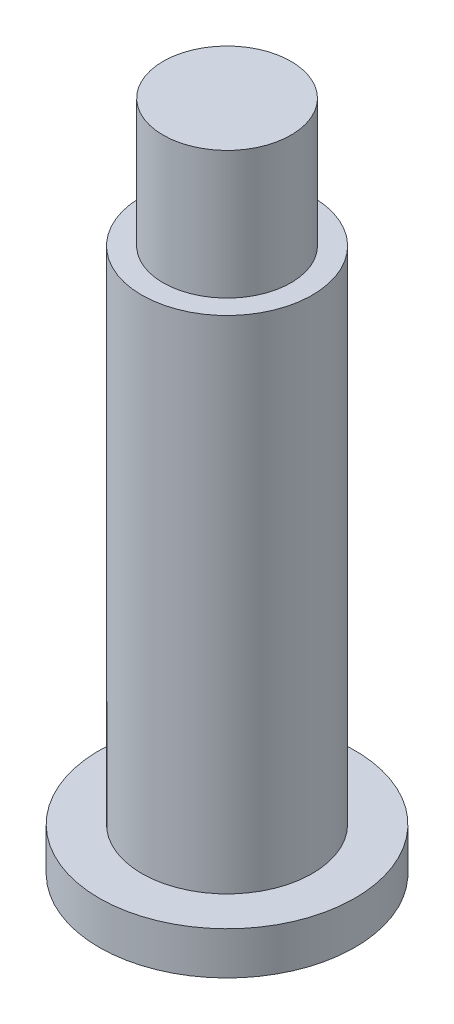
from build123d import *

# Parameters (mm, degrees)
SKETCH_1_R      = 6
EXTRUDE_1_DEPTH = 2
SKETCH_2_R      = 4
EXTRUDE_2_DEPTH = 23.5
SKETCH_3_R      = 3
EXTRUDE_3_DEPTH = 6


with BuildPart() as part:
    # 草图1 → 凸台-拉伸1 (new body)
    with BuildSketch(Plane(origin=(0, 0, 0), x_dir=(1, 0, 0), z_dir=(0, 1, 0))):
        Circle(SKETCH_1_R)
    extrude(amount=EXTRUDE_1_DEPTH)

    # 草图2 → 凸台-拉伸2 (add)
    with BuildSketch(Plane(origin=(0, 2, 0), x_dir=(1, 0, 0), z_dir=(0, 1, 0))):
        Circle(SKETCH_2_R)
    extrude(amount=EXTRUDE_2_DEPTH)

    # 草图3 → 凸台-拉伸3 (add)
    with BuildSketch(Plane(origin=(0, 25.5, 0), x_dir=(1, 0, 0), z_dir=(0, 1, 0))):
        Circle(SKETCH_3_R)
    extrude(amount=EXTRUDE_3_DEPTH)


solid = part.part
